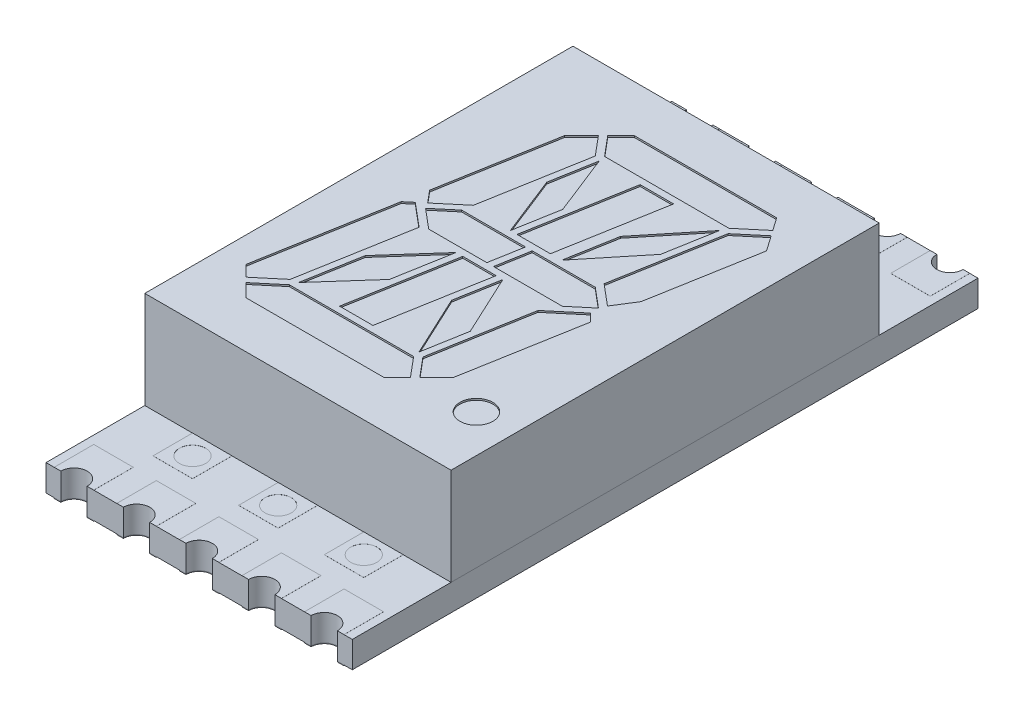
from build123d import *

# Parameters (mm, degrees)
SKETCH1_W          = 9.3
SKETCH1_H          = 13
EXTRUDE2_DEPTH     = 2.95
SKETCH6_R          = 0.5
CUT_EXTRUDE4_DEPTH = 0.05
SKETCH7_W          = 9.3
SKETCH7_H          = 19
EXTRUDE3_DEPTH     = 0.8
SKETCH8_W          = 1.2
SKETCH8_H          = 1.2
SKETCH8_R          = 0.4
EXTRUDE4_DEPTH     = 0.002
EXTRUDE5_DEPTH     = 0.02
EXTRUDE5_2_DEPTH   = 0.02
EXTRUDE5_3_DEPTH   = 0.02
EXTRUDE5_4_DEPTH   = 0.02
EXTRUDE5_5_DEPTH   = 0.02
SKETCH9_W          = 1.2
SKETCH9_H          = 1.2
SKETCH9_R          = 0.4
EXTRUDE5_6_DEPTH   = 0.02
EXTRUDE5_7_DEPTH   = 0.02
EXTRUDE5_8_DEPTH   = 0.02
EXTRUDE5_9_DEPTH   = 0.02
EXTRUDE5_10_DEPTH  = 0.02
EXTRUDE5_11_DEPTH  = 0.02
EXTRUDE5_12_DEPTH  = 0.02
EXTRUDE5_13_DEPTH  = 0.02
EXTRUDE5_14_DEPTH  = 0.02
EXTRUDE5_15_DEPTH  = 0.02
EXTRUDE5_16_DEPTH  = 0.02
SKETCH8_4_R        = 0.4
CUT_EXTRUDE6_DEPTH = 1.82


with BuildPart() as part:
    # Sketch1 → Extrude2 (new body)
    with BuildSketch(Plane(origin=(0, 0, 0), x_dir=(1, 0, 0), z_dir=(0, 1, 0))):
        Rectangle(SKETCH1_W, SKETCH1_H)
    extrude(amount=-EXTRUDE2_DEPTH)

    # Sketch6 → Cut-Extrude4 (cut)
    with BuildSketch(Plane(origin=(0, 0, 0), x_dir=(-1, 0, 0), z_dir=(0, 1, 0))):
        Polygon((1.911081136, -4.533983961), (2.42572527, -4.019339828), (3.039576299, -0.538017644), (2.731918907, -0.171365842), (1.977123917, -0.80471404), (1.422270793, -3.951442478), align=None)
        Polygon((2.936144765, 0), (3.16887751, 0.19528596), (3.874331883, 4.196116524), (3.535814623, 4.534633784), (2.811415935, 3.926791111), (2.224333407, 0.597280648), align=None)
        Polygon((1.365065098, -5.08), (1.769119574, -4.675945524), (1.269061904, -4.08), (-2.506531432, -4.08), (-3.23093012, -4.687842672), (-2.956338603, -5.08), align=None)
        Polygon((2.029123204, -0.5), (2.625, 0), (2.029123204, 0.5), (0.265389965, 0.5), (0.089062984, -0.5), align=None)
        Polygon((2.682858413, 4.08), (3.39385306, 4.676595347), (2.990448407, 5.08), (-1.188738117, 5.08), (-1.592792593, 4.675945524), (-1.092734923, 4.08), align=None)
        Polygon((-3.346083602, -4.523386458), (-2.635088954, -3.926791111), (-2.070732577, -0.726167048), (-2.708443487, -0.191064058), (-3.102281894, -0.817603456), (-3.673309149, -4.056059945), align=None)
        Polygon((-2.029123204, -0.5), (-0.114022338, -0.5), (0.062304642, 0.5), (-2.029123204, 0.5), (-2.625, 0), align=None)
        Polygon((-1.770178078, 0.978362218), (-1.245943812, 3.951442478), (-1.734754156, 4.533983961), (-2.249398289, 4.019339828), (-2.872611309, 0.484923155), (-2.632940493, 0.254418593), align=None)
        Polygon((-0.011395618, -3.88), (0.54932418, -0.7), (-0.466102431, -0.7), (-1.02682223, -3.88), align=None)
        Polygon((0.34147514, 3.88), (-0.219244658, 0.7), (0.796181953, 0.7), (1.356901752, 3.88), align=None)
        Polygon((0.513474233, -2.055069252), (1.231782707, -3.88), (1.470717976, -2.524930748), (0.752409503, -0.7), align=None)
        Polygon((-1.28886399, 2.556275956), (-0.422329981, 0.7), (-0.188921717, 2.023724044), (-1.055455726, 3.88), align=None)
        Polygon((1.302579964, 2.420171733), (0.999267276, 0.7), (2.296767389, 2.159828267), (2.600080077, 3.88), align=None)
        Polygon((-2.423753096, -3.88), (-1.076207276, -2.223474759), (-0.807577572, -0.7), (-2.155123392, -2.356525241), align=None)
        with Locations(Location((-3.5, 4.58, 0), (0, 0, 90))):  # turned: the seam where the file's is
            Circle(SKETCH6_R)
    extrude(amount=-CUT_EXTRUDE4_DEPTH, mode=Mode.SUBTRACT)

    # Sketch8 → Extrude4 (add)
    with BuildSketch(Plane(origin=(0, -2.95, 0), x_dir=(-1, 0, 0), z_dir=(0, 1, 0))):
        with BuildLine():
            Line((4.2, -9.5), (4.4, -9.5))
            Line((4.4, -9.5), (4.4, -8.3))
            Line((4.4, -8.3), (3.2, -8.3))
            Line((3.2, -8.3), (3.2, -9.5))
            Line((3.2, -9.5), (3.4, -9.5))
            ThreePointArc((3.4, -9.5), (3.8, -9.1), (4.2, -9.5))
        make_face()
        with BuildLine():
            Line((2.3, -9.5), (2.5, -9.5))
            Line((2.5, -9.5), (2.5, -8.3))
            Line((2.5, -8.3), (1.3, -8.3))
            Line((1.3, -8.3), (1.3, -9.5))
            Line((1.3, -9.5), (1.5, -9.5))
            ThreePointArc((1.5, -9.5), (1.9, -9.1), (2.3, -9.5))
        make_face()
        with BuildLine():
            Line((0.4, -9.5), (0.6, -9.5))
            Line((0.6, -9.5), (0.6, -8.3))
            Line((0.6, -8.3), (-0.6, -8.3))
            Line((-0.6, -8.3), (-0.6, -9.5))
            Line((-0.6, -9.5), (-0.4, -9.5))
            ThreePointArc((-0.4, -9.5), (0, -9.1), (0.4, -9.5))
        make_face()
        with BuildLine():
            Line((-1.5, -9.5), (-1.3, -9.5))
            Line((-1.3, -9.5), (-1.3, -8.3))
            Line((-1.3, -8.3), (-2.5, -8.3))
            Line((-2.5, -8.3), (-2.5, -9.5))
            Line((-2.5, -9.5), (-2.3, -9.5))
            ThreePointArc((-2.3, -9.5), (-1.9, -9.1), (-1.5, -9.5))
        make_face()
        with BuildLine():
            Line((-3.4, -9.5), (-3.2, -9.5))
            Line((-3.2, -9.5), (-3.2, -8.3))
            Line((-3.2, -8.3), (-4.4, -8.3))
            Line((-4.4, -8.3), (-4.4, -9.5))
            Line((-4.4, -9.5), (-4.2, -9.5))
            ThreePointArc((-4.2, -9.5), (-3.8, -9.1), (-3.4, -9.5))
        make_face()
        with BuildLine():
            Line((-4.2, 9.5), (-4.4, 9.5))
            Line((-4.4, 9.5), (-4.4, 8.3))
            Line((-4.4, 8.3), (-3.2, 8.3))
            Line((-3.2, 8.3), (-3.2, 9.5))
            Line((-3.2, 9.5), (-3.4, 9.5))
            ThreePointArc((-3.4, 9.5), (-3.8, 9.1), (-4.2, 9.5))
        make_face()
        with BuildLine():
            Line((-2.3, 9.5), (-2.5, 9.5))
            Line((-2.5, 9.5), (-2.5, 8.3))
            Line((-2.5, 8.3), (-1.3, 8.3))
            Line((-1.3, 8.3), (-1.3, 9.5))
            Line((-1.3, 9.5), (-1.5, 9.5))
            ThreePointArc((-1.5, 9.5), (-1.9, 9.1), (-2.3, 9.5))
        make_face()
        with BuildLine():
            Line((-0.4, 9.5), (-0.6, 9.5))
            Line((-0.6, 9.5), (-0.6, 8.3))
            Line((-0.6, 8.3), (0.6, 8.3))
            Line((0.6, 8.3), (0.6, 9.5))
            Line((0.6, 9.5), (0.4, 9.5))
            ThreePointArc((0.4, 9.5), (0, 9.1), (-0.4, 9.5))
        make_face()
        with BuildLine():
            Line((1.5, 9.5), (1.3, 9.5))
            Line((1.3, 9.5), (1.3, 8.3))
            Line((1.3, 8.3), (2.5, 8.3))
            Line((2.5, 8.3), (2.5, 9.5))
            Line((2.5, 9.5), (2.3, 9.5))
            ThreePointArc((2.3, 9.5), (1.9, 9.1), (1.5, 9.5))
        make_face()
        with BuildLine():
            Line((3.4, 9.5), (3.2, 9.5))
            Line((3.2, 9.5), (3.2, 8.3))
            Line((3.2, 8.3), (4.4, 8.3))
            Line((4.4, 8.3), (4.4, 9.5))
            Line((4.4, 9.5), (4.2, 9.5))
            ThreePointArc((4.2, 9.5), (3.8, 9.1), (3.4, 9.5))
        make_face()
        with Locations((2.6, -7.1)):
            Rectangle(SKETCH8_W, SKETCH8_H)
        with Locations(Location((2.6, -7.1, 0), (0, 0, 90))):  # turned: the seam where the file's is
            Circle(SKETCH8_R, mode=Mode.SUBTRACT)
        with Locations((0, -7.1)):
            Rectangle(SKETCH8_W, SKETCH8_H)
        with Locations(Location((0, -7.1, 0), (0, 0, 90))):  # turned: the seam where the file's is
            Circle(SKETCH8_R, mode=Mode.SUBTRACT)
        with Locations((-2.6, -7.1)):
            Rectangle(SKETCH8_W, SKETCH8_H)
        with Locations(Location((-2.6, -7.1, 0), (0, 0, 90))):  # turned: the seam where the file's is
            Circle(SKETCH8_R, mode=Mode.SUBTRACT)
        with Locations((-2.6, 7.1)):
            Rectangle(SKETCH8_W, SKETCH8_H)
        with Locations(Location((-2.6, 7.1, 0), (0, 0, 90))):  # turned: the seam where the file's is
            Circle(SKETCH8_R, mode=Mode.SUBTRACT)
        with Locations((0, 7.1)):
            Rectangle(SKETCH8_W, SKETCH8_H)
        with Locations(Location((0, 7.1, 0), (0, 0, 90))):  # turned: the seam where the file's is
            Circle(SKETCH8_R, mode=Mode.SUBTRACT)
        with Locations((2.6, 7.1)):
            Rectangle(SKETCH8_W, SKETCH8_H)
        with Locations(Location((2.6, 7.1, 0), (0, 0, 90))):  # turned: the seam where the file's is
            Circle(SKETCH8_R, mode=Mode.SUBTRACT)
    extrude(amount=EXTRUDE4_DEPTH)


with BuildPart() as body_2:
    # Sketch7 → Extrude3 (new body)
    with BuildSketch(Plane.XZ.offset(2.95)):
        Rectangle(SKETCH7_W, SKETCH7_H)
    extrude(amount=EXTRUDE3_DEPTH)

    # Sketch8_4 → Cut-Extrude6 (cut, through all)
    with BuildSketch(Plane(origin=(0, -2.95, 0), x_dir=(-1, 0, 0), z_dir=(0, 1, 0))):
        with Locations((3.8, -9.5)):
            Circle(SKETCH8_4_R)
        with Locations((1.9, -9.5)):
            Circle(SKETCH8_4_R)
        with Locations((0, -9.5)):
            Circle(SKETCH8_4_R)
        with Locations((-1.9, -9.5)):
            Circle(SKETCH8_4_R)
        with Locations((-3.8, -9.5)):
            Circle(SKETCH8_4_R)
        with Locations((-3.8, 9.5)):
            Circle(SKETCH8_4_R)
        with Locations((-1.9, 9.5)):
            Circle(SKETCH8_4_R)
        with Locations((0, 9.5)):
            Circle(SKETCH8_4_R)
        with Locations((1.9, 9.5)):
            Circle(SKETCH8_4_R)
        with Locations((3.8, 9.5)):
            Circle(SKETCH8_4_R)
    extrude(amount=-CUT_EXTRUDE6_DEPTH, mode=Mode.SUBTRACT)


with BuildPart() as body_3:
    # Sketch9 → Extrude5 (new body)
    with BuildSketch(Plane.XZ.offset(3.75)):
        with BuildLine():
            Line((3.2, 9.5), (3.2, 8.3))
            Line((3.2, 8.3), (4.4, 8.3))
            Line((4.4, 8.3), (4.4, 9.5))
            Line((4.4, 9.5), (4.2, 9.5))
            ThreePointArc((4.2, 9.5), (3.8, 9.1), (3.4, 9.5))
            Line((3.4, 9.5), (3.2, 9.5))
        make_face()
    extrude(amount=EXTRUDE5_DEPTH)


with BuildPart() as body_4:
    # Sketch9 → Extrude5 2 (new body)
    with BuildSketch(Plane.XZ.offset(3.75)):
        with BuildLine():
            Line((2.5, 8.3), (2.5, 9.5))
            Line((2.5, 9.5), (2.3, 9.5))
            ThreePointArc((2.3, 9.5), (1.9, 9.1), (1.5, 9.5))
            Line((1.5, 9.5), (1.3, 9.5))
            Line((1.3, 9.5), (1.3, 8.3))
            Line((1.3, 8.3), (2.5, 8.3))
        make_face()
    extrude(amount=EXTRUDE5_2_DEPTH)


with BuildPart() as body_5:
    # Sketch9 → Extrude5 3 (new body)
    with BuildSketch(Plane.XZ.offset(3.75)):
        with BuildLine():
            Line((0.6, 8.3), (0.6, 9.5))
            Line((0.6, 9.5), (0.4, 9.5))
            ThreePointArc((0.4, 9.5), (0, 9.1), (-0.4, 9.5))
            Line((-0.4, 9.5), (-0.6, 9.5))
            Line((-0.6, 9.5), (-0.6, 8.3))
            Line((-0.6, 8.3), (0.6, 8.3))
        make_face()
    extrude(amount=EXTRUDE5_3_DEPTH)


with BuildPart() as body_6:
    # Sketch9 → Extrude5 4 (new body)
    with BuildSketch(Plane.XZ.offset(3.75)):
        with BuildLine():
            Line((-1.3, 8.3), (-1.3, 9.5))
            Line((-1.3, 9.5), (-1.5, 9.5))
            ThreePointArc((-1.5, 9.5), (-1.9, 9.1), (-2.3, 9.5))
            Line((-2.3, 9.5), (-2.5, 9.5))
            Line((-2.5, 9.5), (-2.5, 8.3))
            Line((-2.5, 8.3), (-1.3, 8.3))
        make_face()
    extrude(amount=EXTRUDE5_4_DEPTH)


with BuildPart() as body_7:
    # Sketch9 → Extrude5 5 (new body)
    with BuildSketch(Plane.XZ.offset(3.75)):
        with BuildLine():
            Line((-3.2, 8.3), (-3.2, 9.5))
            Line((-3.2, 9.5), (-3.4, 9.5))
            ThreePointArc((-3.4, 9.5), (-3.8, 9.1), (-4.2, 9.5))
            Line((-4.2, 9.5), (-4.4, 9.5))
            Line((-4.4, 9.5), (-4.4, 8.3))
            Line((-4.4, 8.3), (-3.2, 8.3))
        make_face()
    extrude(amount=EXTRUDE5_5_DEPTH)


with BuildPart() as body_8:
    # Sketch9 → Extrude5 6 (new body)
    with BuildSketch(Plane.XZ.offset(3.75)):
        with Locations((-2.6, 7.1)):
            Rectangle(SKETCH9_W, SKETCH9_H)
        with Locations(Location((-2.6, 7.1, 0), (0, 0, 270))):  # turned: the seam where the file's is
            Circle(SKETCH9_R, mode=Mode.SUBTRACT)
    extrude(amount=EXTRUDE5_6_DEPTH)


with BuildPart() as body_9:
    # Sketch9 → Extrude5 7 (new body)
    with BuildSketch(Plane.XZ.offset(3.75)):
        with Locations((0, 7.1)):
            Rectangle(SKETCH9_W, SKETCH9_H)
        with Locations(Location((0, 7.1, 0), (0, 0, 270))):  # turned: the seam where the file's is
            Circle(SKETCH9_R, mode=Mode.SUBTRACT)
    extrude(amount=EXTRUDE5_7_DEPTH)


with BuildPart() as body_10:
    # Sketch9 → Extrude5 8 (new body)
    with BuildSketch(Plane.XZ.offset(3.75)):
        with Locations((2.6, 7.1)):
            Rectangle(SKETCH9_W, SKETCH9_H)
        with Locations(Location((2.6, 7.1, 0), (0, 0, 270))):  # turned: the seam where the file's is
            Circle(SKETCH9_R, mode=Mode.SUBTRACT)
    extrude(amount=EXTRUDE5_8_DEPTH)


with BuildPart() as body_11:
    # Sketch9 → Extrude5 9 (new body)
    with BuildSketch(Plane.XZ.offset(3.75)):
        with BuildLine():
            Line((3.2, -8.3), (3.2, -9.5))
            Line((3.2, -9.5), (3.4, -9.5))
            ThreePointArc((3.4, -9.5), (3.8, -9.1), (4.2, -9.5))
            Line((4.2, -9.5), (4.4, -9.5))
            Line((4.4, -9.5), (4.4, -8.3))
            Line((4.4, -8.3), (3.2, -8.3))
        make_face()
    extrude(amount=EXTRUDE5_9_DEPTH)


with BuildPart() as body_12:
    # Sketch9 → Extrude5 10 (new body)
    with BuildSketch(Plane.XZ.offset(3.75)):
        with BuildLine():
            Line((1.3, -8.3), (1.3, -9.5))
            Line((1.3, -9.5), (1.5, -9.5))
            ThreePointArc((1.5, -9.5), (1.9, -9.1), (2.3, -9.5))
            Line((2.3, -9.5), (2.5, -9.5))
            Line((2.5, -9.5), (2.5, -8.3))
            Line((2.5, -8.3), (1.3, -8.3))
        make_face()
    extrude(amount=EXTRUDE5_10_DEPTH)


with BuildPart() as body_13:
    # Sketch9 → Extrude5 11 (new body)
    with BuildSketch(Plane.XZ.offset(3.75)):
        with BuildLine():
            Line((-0.6, -8.3), (-0.6, -9.5))
            Line((-0.6, -9.5), (-0.4, -9.5))
            ThreePointArc((-0.4, -9.5), (0, -9.1), (0.4, -9.5))
            Line((0.4, -9.5), (0.6, -9.5))
            Line((0.6, -9.5), (0.6, -8.3))
            Line((0.6, -8.3), (-0.6, -8.3))
        make_face()
    extrude(amount=EXTRUDE5_11_DEPTH)


with BuildPart() as body_14:
    # Sketch9 → Extrude5 12 (new body)
    with BuildSketch(Plane.XZ.offset(3.75)):
        with BuildLine():
            Line((-2.5, -8.3), (-2.5, -9.5))
            Line((-2.5, -9.5), (-2.3, -9.5))
            ThreePointArc((-2.3, -9.5), (-1.9, -9.1), (-1.5, -9.5))
            Line((-1.5, -9.5), (-1.3, -9.5))
            Line((-1.3, -9.5), (-1.3, -8.3))
            Line((-1.3, -8.3), (-2.5, -8.3))
        make_face()
    extrude(amount=EXTRUDE5_12_DEPTH)


with BuildPart() as body_15:
    # Sketch9 → Extrude5 13 (new body)
    with BuildSketch(Plane.XZ.offset(3.75)):
        with BuildLine():
            Line((-4.4, -8.3), (-4.4, -9.5))
            Line((-4.4, -9.5), (-4.2, -9.5))
            ThreePointArc((-4.2, -9.5), (-3.8, -9.1), (-3.4, -9.5))
            Line((-3.4, -9.5), (-3.2, -9.5))
            Line((-3.2, -9.5), (-3.2, -8.3))
            Line((-3.2, -8.3), (-4.4, -8.3))
        make_face()
    extrude(amount=EXTRUDE5_13_DEPTH)


with BuildPart() as body_16:
    # Sketch9 → Extrude5 14 (new body)
    with BuildSketch(Plane.XZ.offset(3.75)):
        with Locations((-2.6, -7.1)):
            Rectangle(SKETCH9_W, SKETCH9_H)
        with Locations(Location((-2.6, -7.1, 0), (0, 0, 270))):  # turned: the seam where the file's is
            Circle(SKETCH9_R, mode=Mode.SUBTRACT)
    extrude(amount=EXTRUDE5_14_DEPTH)


with BuildPart() as body_17:
    # Sketch9 → Extrude5 15 (new body)
    with BuildSketch(Plane.XZ.offset(3.75)):
        with Locations((0, -7.1)):
            Rectangle(SKETCH9_W, SKETCH9_H)
        with Locations(Location((0, -7.1, 0), (0, 0, 270))):  # turned: the seam where the file's is
            Circle(SKETCH9_R, mode=Mode.SUBTRACT)
    extrude(amount=EXTRUDE5_15_DEPTH)


with BuildPart() as body_18:
    # Sketch9 → Extrude5 16 (new body)
    with BuildSketch(Plane.XZ.offset(3.75)):
        with Locations((2.6, -7.1)):
            Rectangle(SKETCH9_W, SKETCH9_H)
        with Locations(Location((2.6, -7.1, 0), (0, 0, 270))):  # turned: the seam where the file's is
            Circle(SKETCH9_R, mode=Mode.SUBTRACT)
    extrude(amount=EXTRUDE5_16_DEPTH)


solid = Compound([part.part, body_2.part, body_3.part, body_4.part, body_5.part, body_6.part, body_7.part, body_8.part, body_9.part, body_10.part, body_11.part, body_12.part, body_13.part, body_14.part, body_15.part, body_16.part, body_17.part, body_18.part])
